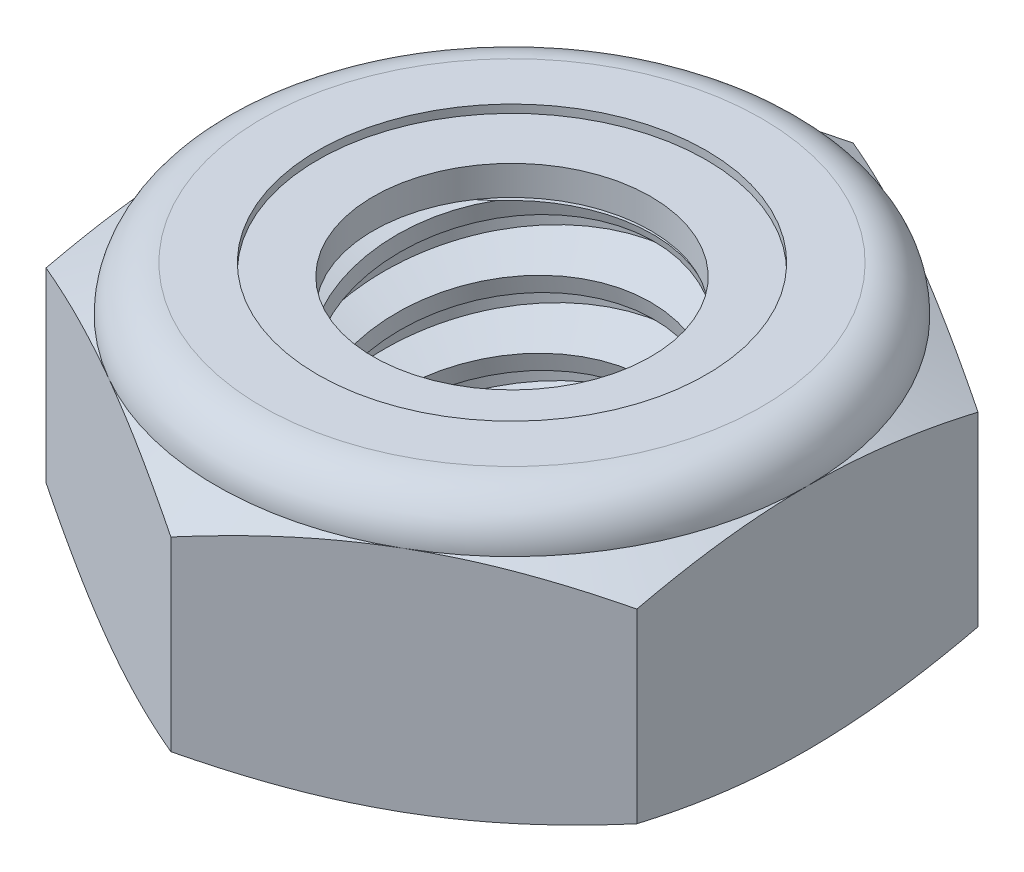
from build123d import *

# Parameters (mm, degrees)
EXTRUDE1_DEPTH      = 5.159375
SKETCH2_W           = 3.175
SKETCH2_H           = 5.159375
LPATTERN1_COUNT     = 4
LPATTERN1_PITCH     = 1.27
LPATTERN1_COL_COUNT = 2
LPATTERN1_COL_PITCH = 1.27


with BuildPart() as part:
    # Sketch1 → Extrude1 (new body)
    with BuildSketch(Plane(origin=(0, 0, 0), x_dir=(1, 0, 0), z_dir=(0, 1, 0))):
        Polygon((0, 6.415804866), (-5.55625, 3.207902433), (-5.55625, -3.207902433), (0, -6.415804866), (5.55625, -3.207902433), (5.55625, 3.207902433), align=None)
    extrude(amount=EXTRUDE1_DEPTH)

    # Sketch4 → Cut-Revolve2 (revolve, cut)
    with BuildSketch(Plane(origin=(0, 0, 0), x_dir=(0, 0, -1), z_dir=(1, 0, 0)), mode=Mode.PRIVATE) as cut_revolve2_sk:
        Polygon((0, 5.159375), (3.175, 5.159375), (2.609908356, 4.895868439), (2.609908356, 0.263506561), (3.175, 0), (0, 0), align=None)
    revolve(cut_revolve2_sk.sketch.rotate(Axis((0, 5.159375, 0), (0, 1, 0)), 34.505533911), axis=Axis((0, 5.159375, 0), (0, 1, 0)), mode=Mode.SUBTRACT)  # turned: the seam where the file's is


with BuildPart() as body_2:
    # Sketch2 → Revolve1 (revolve)
    with BuildSketch(Plane(origin=(0, 0, 0), x_dir=(0, 0, -1), z_dir=(1, 0, 0))):
        with Locations((1.5875, 2.5796875)):
            Rectangle(SKETCH2_W, SKETCH2_H)
    revolve(axis=Axis((0, -3.175, 0), (0, 1, 0)))

    # Sketch3 → Cut-Revolve1 (revolve, cut)
    with BuildSketch(Plane(origin=(0, 0, 0), x_dir=(0, 0, -1), z_dir=(1, 0, 0)), mode=Mode.PRIVATE) as cut_revolve1_sk:
        Polygon((3.206133436, 5.003707818), (3.424067492, 3.914037542), (2.672175229, 4.168393763), (2.609908356, 4.479728128), align=None)
    cut_revolve1 = revolve(cut_revolve1_sk.sketch.rotate(Axis((0, 5.159375, 0.272704483), (0, -0.980580676, -0.196116135)), 180), axis=Axis((0, 5.159375, 0.272704483), (0, -0.980580676, -0.196116135)), mode=Mode.SUBTRACT)  # turned: the seam where the file's is

    # LPattern1: Cut-Revolve1 ×4
    with Locations(*[(0, -i * LPATTERN1_PITCH, 0) for i in range(1, LPATTERN1_COUNT)]):
        add(cut_revolve1, mode=Mode.SUBTRACT)

    # LPattern1 col: Cut-Revolve1 ×2
    with Locations(*[(0, i * LPATTERN1_COL_PITCH, 0) for i in range(1, LPATTERN1_COL_COUNT)]):
        add(cut_revolve1, mode=Mode.SUBTRACT)


with BuildPart() as part_1:
    add(part.part)

    # Combine1: cut body 2
    add(body_2.part, mode=Mode.SUBTRACT)

    # Sketch5 → Cut-Revolve3 (revolve, cut)
    with BuildSketch(Plane(origin=(0, 0, 0), x_dir=(0, 0, -1), z_dir=(1, 0, 0)), mode=Mode.PRIVATE) as cut_revolve3_sk:
        with BuildLine():
            Line((0, 0), (5.55625, 0))
            Line((5.55625, 0), (6.415804866, 0.400817017))
            Line((6.415804866, 0.400817017), (6.415804866, 3.89866215))
            Line((6.415804866, 3.89866215), (5.55625, 4.299479167))
            ThreePointArc((5.55625, 4.299479167), (5.304392342, 4.907517342), (4.696354167, 5.159375))
            Line((4.696354167, 5.159375), (4.696354167, 6.429375))
            Line((4.696354167, 6.429375), (7.685804866, 6.429375))
            Line((7.685804866, 6.429375), (7.685804866, -1.27))
            Line((7.685804866, -1.27), (0, -1.27))
            Line((0, -1.27), (0, 0))
        make_face()
    revolve(cut_revolve3_sk.sketch.rotate(Axis((0, 0, 0), (0, 1, 0)), 54.619043446), axis=Axis((0, 0, 0), (0, 1, 0)), mode=Mode.SUBTRACT)  # turned: the seam where the file's is

    # Sketch6 → Cut-Revolve4 (revolve, cut)
    with BuildSketch(Plane(origin=(0, 0, 0), x_dir=(0, 0, -1), z_dir=(1, 0, 0)), mode=Mode.PRIVATE) as cut_revolve4_sk:
        with BuildLine():
            Line((0, 4.299479167), (5.40385, 4.299479167))
            ThreePointArc((5.40385, 4.299479167), (5.196629268, 4.799754268), (4.696354167, 5.006975))
            Line((4.696354167, 5.006975), (3.653131261, 5.006975))
            Line((3.653131261, 5.006975), (3.653131261, 6.429375))
            Line((3.653131261, 6.429375), (0, 6.429375))
            Line((0, 6.429375), (0, 4.299479167))
        make_face()
    revolve(cut_revolve4_sk.sketch.rotate(Axis((0, 6.429375, 0), (0, 1, 0)), 54.619043446), axis=Axis((0, 6.429375, 0), (0, 1, 0)), mode=Mode.SUBTRACT)  # turned: the seam where the file's is


with BuildPart() as body_2_2:
    # Sketch7 → Revolve2 (revolve)
    with BuildSketch(Plane(origin=(0, 0, 0), x_dir=(0, 0, -1), z_dir=(1, 0, 0))):
        with BuildLine():
            Line((2.609908356, 4.375679167), (5.3230343, 4.375679167))
            ThreePointArc((5.3230343, 4.375679167), (5.114940888, 4.772046184), (4.696354167, 4.930775))
            Line((4.696354167, 4.930775), (2.609908356, 4.930775))
            Line((2.609908356, 4.930775), (2.609908356, 4.375679167))
        make_face()
    revolve(axis=Axis((0, 4.375679167, 0), (0, 1, 0)))


solid = Compound([part_1.part, body_2_2.part])
